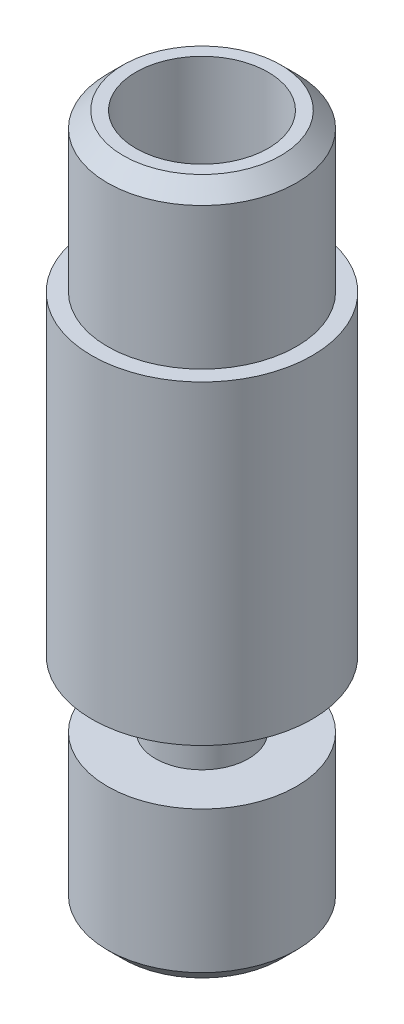
from build123d import *

# Parameters (mm, degrees)
CHAMFER1_SIZE = 0.5


with BuildPart() as part:
    # Sketch1 → Revolve1 (revolve)
    with BuildSketch(Plane.XY):
        Polygon((1.475, 0), (3.5, 0), (3.5, 10), (3, 10), (3, 15), (0, 15), (0, -7.1), (3, -7.1), (3, -2.1), (1.475, -2.1), align=None)
    revolve(axis=Axis((0, 0, 0), (0, 1, 0)))

    # Sketch2 → Cut-Revolve1 (revolve, cut)
    with BuildSketch(Plane.XY):
        Polygon((0, 15), (2.1, 15), (2.1, 10), (1, 9.339053319), (1, -7.1), (0, -7.1), align=None)
    revolve(axis=Axis((0, 15, 0), (0, -1, 0)), mode=Mode.SUBTRACT)

    # Chamfer1
    chamfer1_edges = [part.edges().sort_by_distance(p)[0] for p in [
        (-3, -7.1, 0),
        (-3, 15, 0),
    ]]
    chamfer(chamfer1_edges, length=CHAMFER1_SIZE)


solid = part.part
